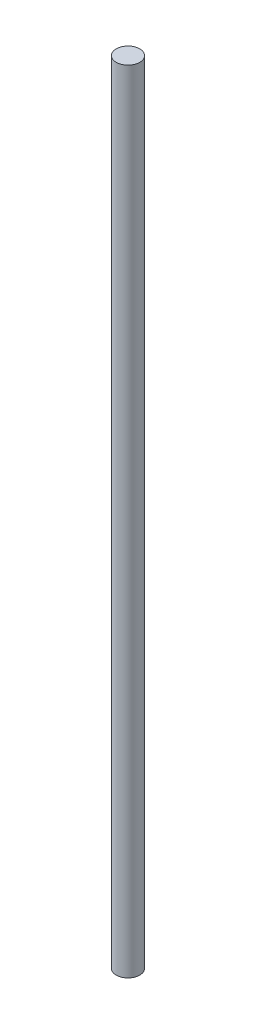
from build123d import *

# Parameters (mm, degrees)
SKETCH1_R           = 5.55625
BOSS_EXTRUDE1_DEPTH = 375


with BuildPart() as part:
    # Sketch1 → Boss-Extrude1 (new body)
    with BuildSketch(Plane(origin=(0, 0, 0), x_dir=(1, 0, 0), z_dir=(0, 1, 0))):
        Circle(SKETCH1_R)
    extrude(amount=BOSS_EXTRUDE1_DEPTH)


solid = part.part
